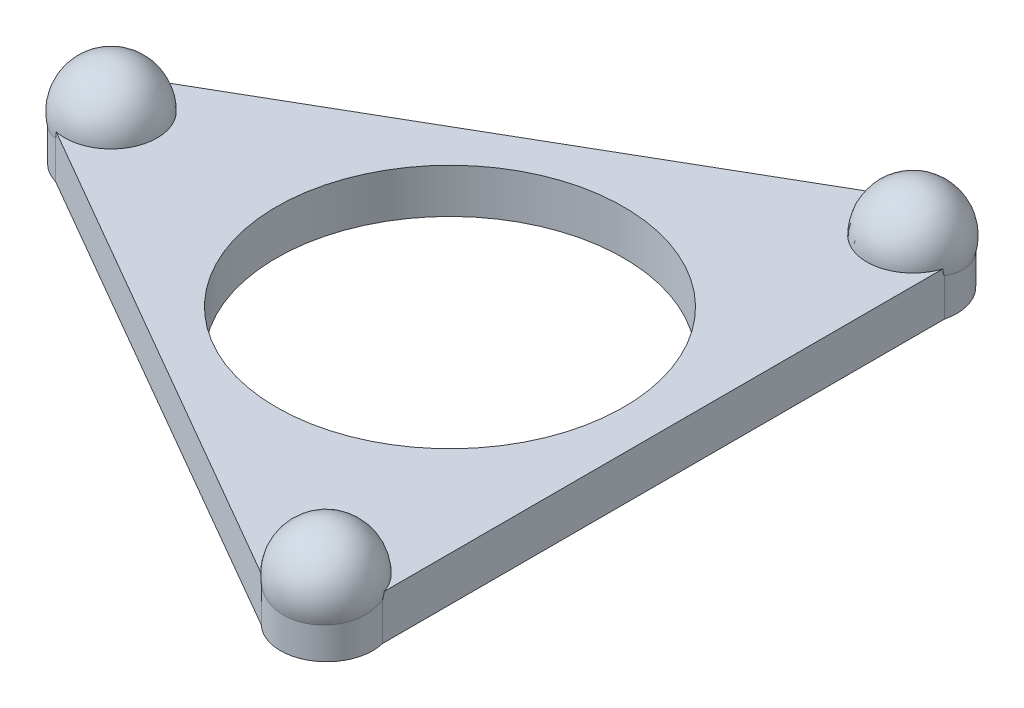
from build123d import *

# Parameters (mm, degrees)
SKETCH1_R           = 5.969
BOSS_EXTRUDE1_DEPTH = 1.524
CIRPATTERN2_COUNT   = 3


with BuildPart() as part:
    # Sketch1 → Boss-Extrude1 (new body)
    with BuildSketch(Plane(origin=(0, 0, 0), x_dir=(1, 0, 0), z_dir=(0, 1, 0))):
        with BuildLine():
            Line((4.697427285, 11.184182722), (-12.0345, 1.524))
            ThreePointArc((-12.0345, 1.524), (-13.1775, 0), (-12.0345, -1.524))
            Line((-12.0345, -1.524), (4.697427285, -11.184182722))
            ThreePointArc((4.697427285, -11.184182722), (6.58875, -11.412049758), (7.337072715, -9.660182722))
            Line((7.337072715, -9.660182722), (7.337072715, 9.660182722))
            ThreePointArc((7.337072715, 9.660182722), (6.58875, 11.412049758), (4.697427285, 11.184182722))
        make_face()
        Circle(SKETCH1_R, mode=Mode.SUBTRACT)
    extrude(amount=BOSS_EXTRUDE1_DEPTH)

    # Sketch2 → Revolve1 (revolve)
    with BuildSketch(Plane(origin=(0, 1.524, 0), x_dir=(1, 0, 0), z_dir=(0, 1, 0))):
        with BuildLine():
            Line((-11.65220136, -1.5875), (-11.65220136, 1.5875))
            ThreePointArc((-11.65220136, 1.5875), (-10.06470136, 0), (-11.65220136, -1.5875))
        make_face()
    revolve1 = revolve(axis=Axis((-11.65220136, 1.524, 1.5875), (0, 0, -1)))

    # CirPattern2: Revolve1 ×3 about axis
    cirpattern2_axis = Axis((0, 0, 0), (0, 1, 0))
    for i in range(1, CIRPATTERN2_COUNT):
        add(revolve1.rotate(cirpattern2_axis, i * 360 / CIRPATTERN2_COUNT))


solid = part.part
